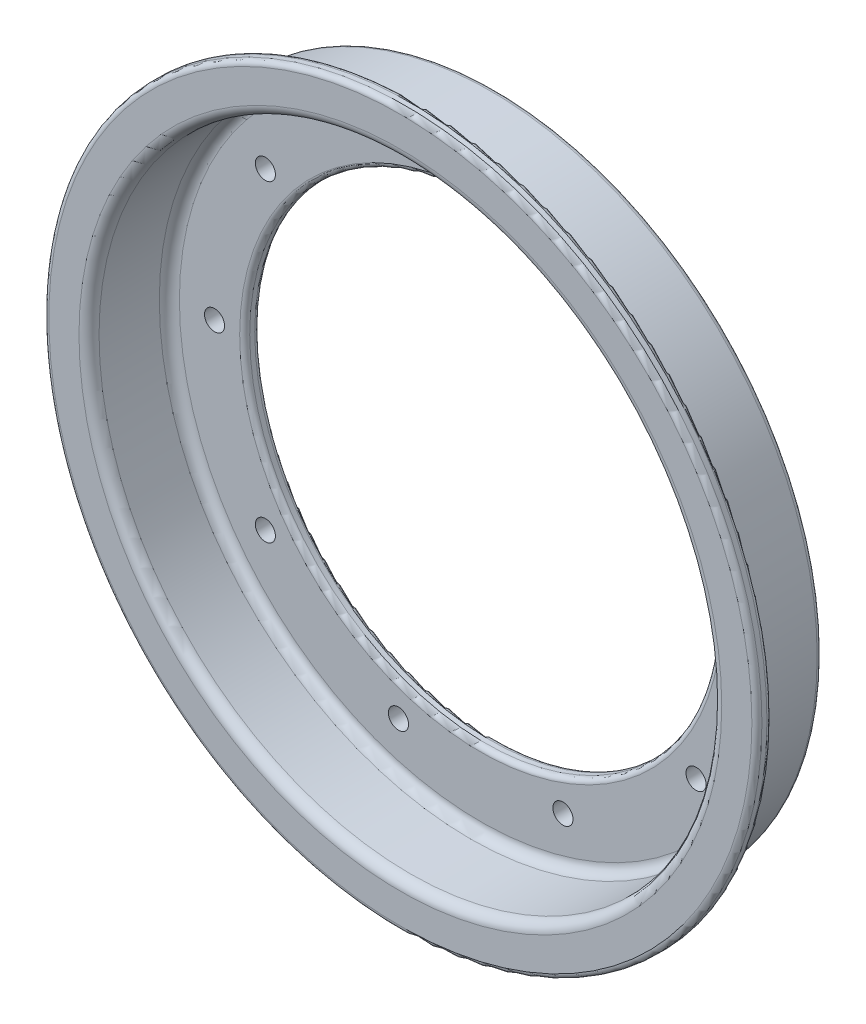
from build123d import *

# Parameters (mm, degrees)
SKETCH_2_R               = 71
SKETCH_2_R_2             = 62
EXTRUDE_1_DEPTH          = 3
SKETCH_3_R               = 65
SKETCH_3_R_2             = 62
EXTRUDE_2_DEPTH          = 16
SKETCH_4_R               = 65
SKETCH_4_R_2             = 47
EXTRUDE_3_DEPTH          = 3
FILLET_1_R               = 2
FILLET_2_R               = 1
FILLET_3_R               = 2
FILLET_4_R               = 1
FILLET_5_R               = 1
SKETCH_5_R               = 2
CUT_EXTRUDE_1_DEPTH      = 1.0000001
CUT_EXTRUDE_1_DEPTH_BACK = 20


with BuildPart() as part:
    # 草图2 → 凸台-拉伸1 (new body)
    with BuildSketch(Plane.XY):
        Circle(SKETCH_2_R)
        Circle(SKETCH_2_R_2, mode=Mode.SUBTRACT)
    extrude(amount=EXTRUDE_1_DEPTH)

    # 草图3 → 凸台-拉伸2 (add)
    with BuildSketch(Plane(origin=(0, 0, 0), x_dir=(-1, 0, 0), z_dir=(0, 0, -1))):
        Circle(SKETCH_3_R)
        Circle(SKETCH_3_R_2, mode=Mode.SUBTRACT)
    extrude(amount=EXTRUDE_2_DEPTH)

    # 草图4 → 凸台-拉伸3 (add)
    with BuildSketch(Plane(origin=(0, 0, -13), x_dir=(-1, 0, 0), z_dir=(0, 0, -1))):
        Circle(SKETCH_4_R)
        Circle(SKETCH_4_R_2, mode=Mode.SUBTRACT)
    extrude(amount=EXTRUDE_3_DEPTH)

    # 圆角1
    fillet_1_edges = [part.edges().sort_by_distance(p)[0] for p in [
        (62, 0, -13),
    ]]
    fillet(fillet_1_edges, radius=FILLET_1_R)

    # 圆角2
    fillet_2_edges = [part.edges().sort_by_distance(p)[0] for p in [
        (47, 0, -13),
        (47, 0, -16),
    ]]
    fillet(fillet_2_edges, radius=FILLET_2_R)

    # 圆角3
    fillet_3_edges = [part.edges().sort_by_distance(p)[0] for p in [
        (-62, 0, 3),
    ]]
    fillet(fillet_3_edges, radius=FILLET_3_R)

    # 圆角4
    fillet_4_edges = [part.edges().sort_by_distance(p)[0] for p in [
        (-71, 0, 0),
        (-71, 0, 3),
    ]]
    fillet(fillet_4_edges, radius=FILLET_4_R)

    # 圆角5
    fillet_5_edges = [part.edges().sort_by_distance(p)[0] for p in [
        (65, 0, -16),
    ]]
    fillet(fillet_5_edges, radius=FILLET_5_R)

    # 草图5 → 切除-拉伸1 (cut, two sides)
    with BuildSketch(Plane.XY.offset(3)) as cut_extrude_1_sk:
        with Locations((42.877900702, 31.152618372)):
            Circle(SKETCH_5_R)
        with Locations((53, 0)):
            Circle(SKETCH_5_R)
        with Locations((42.877900702, -31.152618371)):
            Circle(SKETCH_5_R)
        with Locations((16.377900702, -50.405995364)):
            Circle(SKETCH_5_R)
        with Locations((-16.377900702, -50.405995364)):
            Circle(SKETCH_5_R)
        with Locations((-42.877900702, -31.152618372)):
            Circle(SKETCH_5_R)
        with Locations((-53, 0)):
            Circle(SKETCH_5_R)
        with Locations((-42.877900702, 31.152618371)):
            Circle(SKETCH_5_R)
        with Locations((-16.377900702, 50.405995364)):
            Circle(SKETCH_5_R)
        with Locations((16.377900702, 50.405995364)):
            Circle(SKETCH_5_R)
    extrude(amount=CUT_EXTRUDE_1_DEPTH, mode=Mode.SUBTRACT)
    extrude(cut_extrude_1_sk.sketch, amount=-CUT_EXTRUDE_1_DEPTH_BACK, mode=Mode.SUBTRACT)


solid = part.part
